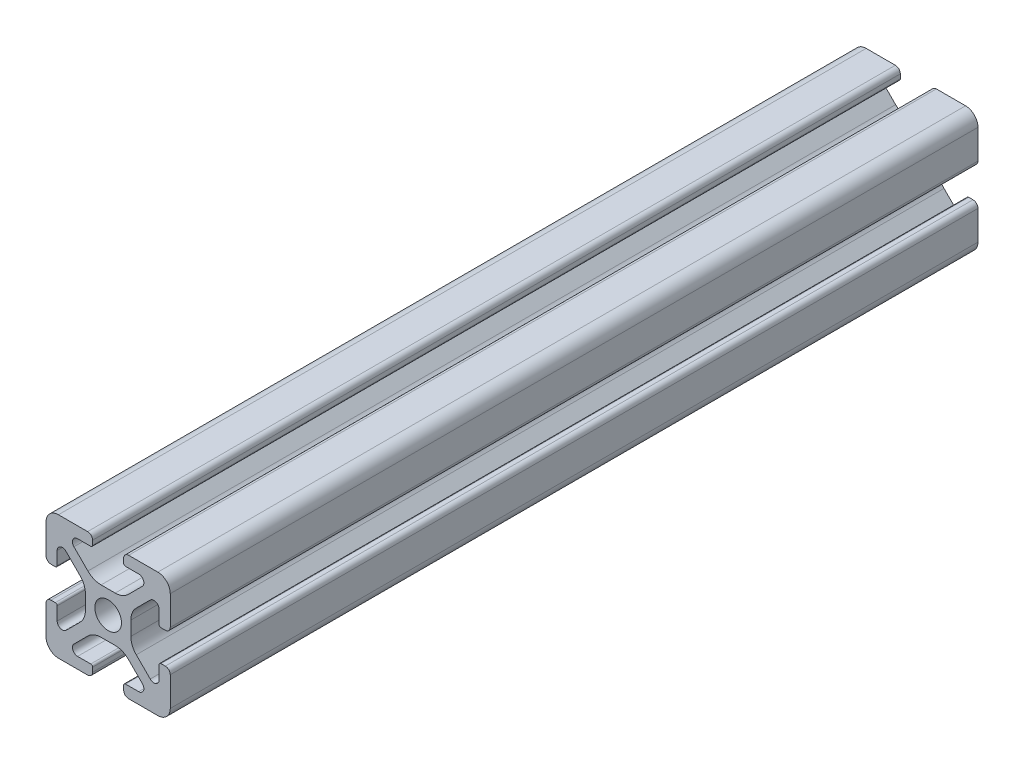
from build123d import *

# Parameters (mm, degrees)
SKETCH4_W              = 20
SKETCH4_H              = 20
BODY_DEPTH             = 130
SKETCH16_OUTSIDE_W     = 48.608
SKETCH16_OUTSIDE_H     = 48.608
SKETCH16_OUTSIDE_R     = 2.15
CUT_PROFILE_DEPTH      = 26
CUT_PROFILE_DEPTH_BACK = 106


with BuildPart() as part:
    # Sketch4 → Body (new body)
    with BuildSketch(Plane.XY.offset(25)):
        Rectangle(SKETCH4_W, SKETCH4_H)
    extrude(amount=-BODY_DEPTH)

    # Sketch16 outside → Cut-Profile (cut, two sides)
    with BuildSketch(Plane.XY) as cut_profile_sk:
        Rectangle(SKETCH16_OUTSIDE_W, SKETCH16_OUTSIDE_H)
        with BuildLine():
            Line((4.917588389, -8.199999991), (2.799999989, -8.199999991))
            ThreePointArc((2.799999989, -8.199999991), (2.587867955, -8.287867957), (2.499999989, -8.499999991))
            Line((2.499999989, -8.499999991), (2.499999989, -9.199999991))
            ThreePointArc((2.499999989, -9.199999991), (2.734314564, -9.765685416), (3.299999989, -9.999999991))
            Line((3.299999989, -9.999999991), (7.999999989, -9.999999991))
            ThreePointArc((7.999999989, -9.999999991), (9.414213552, -9.414213554), (9.999999989, -7.999999991))
            Line((9.999999989, -7.999999991), (9.999999989, -3.299999991))
            ThreePointArc((9.999999989, -3.299999991), (9.765685414, -2.734314566), (9.199999989, -2.499999991))
            Line((9.199999989, -2.499999991), (8.499999989, -2.499999991))
            ThreePointArc((8.499999989, -2.499999991), (8.287867955, -2.587867957), (8.199999989, -2.799999991))
            Line((8.199999989, -2.799999991), (8.199999989, -4.917588391))
            ThreePointArc((8.199999989, -4.917588391), (7.686138511, -5.686636441), (6.778984485, -5.506192286))
            Line((6.778984485, -5.506192286), (4.528679645, -3.255887446))
            ThreePointArc((4.528679645, -3.255887446), (3.878361392, -2.282617401), (3.64999999, -1.134567106))
            Line((3.64999999, -1.134567106), (3.64999999, 1.134567104))
            ThreePointArc((3.64999999, 1.134567104), (3.878361393, 2.282617402), (4.528679647, 3.255887448))
            Line((4.528679647, 3.255887448), (6.778984487, 5.506192288))
            ThreePointArc((6.778984487, 5.506192288), (7.686138506, 5.686636442), (8.199999981, 4.917588398))
            Line((8.199999981, 4.917588398), (8.199999981, 2.799999998))
            ThreePointArc((8.199999981, 2.799999998), (8.287867946, 2.587867964), (8.499999981, 2.499999998))
            Line((8.499999981, 2.499999998), (9.199999981, 2.499999998))
            ThreePointArc((9.199999981, 2.499999998), (9.765685406, 2.734314573), (9.999999981, 3.299999998))
            Line((9.999999981, 3.299999998), (9.999999981, 7.999999998))
            ThreePointArc((9.999999981, 7.999999998), (9.414213543, 9.41421356), (7.999999981, 9.999999998))
            Line((7.999999981, 9.999999998), (3.299999981, 9.999999998))
            ThreePointArc((3.299999981, 9.999999998), (2.734314556, 9.765685423), (2.499999981, 9.199999998))
            Line((2.499999981, 9.199999998), (2.499999981, 8.499999998))
            ThreePointArc((2.499999981, 8.499999998), (2.587867946, 8.287867964), (2.799999981, 8.199999998))
            Line((2.799999981, 8.199999998), (4.917588381, 8.199999998))
            ThreePointArc((4.917588381, 8.199999998), (5.68663643, 7.68613852), (5.506192275, 6.778984494))
            Line((5.506192275, 6.778984494), (3.255887435, 4.528679654))
            ThreePointArc((3.255887435, 4.528679654), (2.28261739, 3.878361401), (1.134567095, 3.649999999))
            Line((1.134567095, 3.649999999), (-1.134567115, 3.649999999))
            ThreePointArc((-1.134567115, 3.649999999), (-2.282617412, 3.878361401), (-3.255887459, 4.528679655))
            Line((-3.255887459, 4.528679655), (-5.506192299, 6.778984495))
            ThreePointArc((-5.506192299, 6.778984495), (-5.686636452, 7.686138515), (-4.917588409, 8.199999989))
            Line((-4.917588409, 8.199999989), (-2.800000009, 8.199999989))
            ThreePointArc((-2.800000009, 8.199999989), (-2.587867974, 8.287867955), (-2.500000009, 8.499999989))
            Line((-2.500000009, 8.499999989), (-2.500000009, 9.199999989))
            ThreePointArc((-2.500000009, 9.199999989), (-2.734314584, 9.765685414), (-3.300000009, 9.999999989))
            Line((-3.300000009, 9.999999989), (-8.000000009, 9.999999989))
            ThreePointArc((-8.000000009, 9.999999989), (-9.414213571, 9.414213552), (-10.000000009, 7.999999989))
            Line((-10.000000009, 7.999999989), (-10.000000009, 3.299999989))
            ThreePointArc((-10.000000009, 3.299999989), (-9.765685434, 2.734314564), (-9.200000009, 2.499999989))
            Line((-9.200000009, 2.499999989), (-8.500000009, 2.499999989))
            ThreePointArc((-8.500000009, 2.499999989), (-8.287867974, 2.587867955), (-8.200000009, 2.799999989))
            Line((-8.200000009, 2.799999989), (-8.200000009, 4.917588389))
            ThreePointArc((-8.200000009, 4.917588389), (-7.686138531, 5.686636438), (-6.778984504, 5.506192284))
            Line((-6.778984504, 5.506192284), (-4.528679664, 3.255887444))
            ThreePointArc((-4.528679664, 3.255887444), (-3.878361412, 2.282617399), (-3.650000009, 1.134567104))
            Line((-3.650000009, 1.134567104), (-3.650000009, -1.134567106))
            ThreePointArc((-3.650000009, -1.134567106), (-3.878361412, -2.282617404), (-4.528679666, -3.25588745))
            Line((-4.528679666, -3.25588745), (-6.778984506, -5.50619229))
            ThreePointArc((-6.778984506, -5.50619229), (-7.686138526, -5.686636444), (-8.2, -4.9175884))
            Line((-8.2, -4.9175884), (-8.2, -2.8))
            ThreePointArc((-8.2, -2.8), (-8.287867966, -2.587867966), (-8.5, -2.5))
            Line((-8.5, -2.5), (-9.2, -2.5))
            ThreePointArc((-9.2, -2.5), (-9.765685425, -2.734314575), (-10, -3.3))
            Line((-10, -3.3), (-10, -8))
            ThreePointArc((-10, -8), (-9.414213562, -9.414213562), (-8, -10))
            Line((-8, -10), (-3.3, -10))
            ThreePointArc((-3.3, -10), (-2.734314575, -9.765685425), (-2.5, -9.2))
            Line((-2.5, -9.2), (-2.5, -8.5))
            ThreePointArc((-2.5, -8.5), (-2.587867966, -8.287867966), (-2.8, -8.2))
            Line((-2.8, -8.2), (-4.9175884, -8.2))
            ThreePointArc((-4.9175884, -8.2), (-5.686636449, -7.686138522), (-5.506192294, -6.778984496))
            Line((-5.506192294, -6.778984496), (-3.255887454, -4.528679656))
            ThreePointArc((-3.255887454, -4.528679656), (-2.282617409, -3.878361403), (-1.134567114, -3.650000001))
            Line((-1.134567114, -3.650000001), (1.134567096, -3.650000001))
            ThreePointArc((1.134567096, -3.650000001), (2.282617393, -3.878361403), (3.255887439, -4.528679657))
            Line((3.255887439, -4.528679657), (5.506192279, -6.778984497))
            ThreePointArc((5.506192279, -6.778984497), (5.686636433, -7.686138517), (4.917588389, -8.199999991))
        make_face(mode=Mode.SUBTRACT)
        Circle(SKETCH16_OUTSIDE_R)
    extrude(amount=CUT_PROFILE_DEPTH, mode=Mode.SUBTRACT)
    extrude(cut_profile_sk.sketch, amount=-CUT_PROFILE_DEPTH_BACK, mode=Mode.SUBTRACT)


solid = part.part
